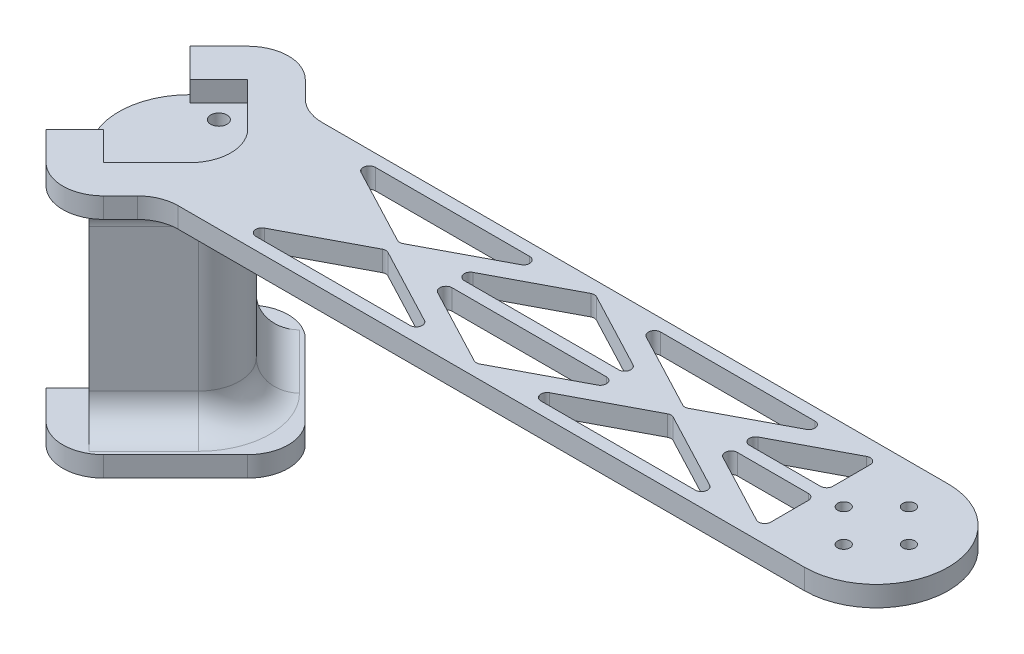
from build123d import *

# Parameters (mm, degrees)
SKETCH1_R            = 1.5
BOSS_EXTRUDE1_DEPTH  = 5
SKETCH2_R            = 2
BOSS_EXTRUDE13_DEPTH = 50
FILLET3_R            = 10
FILLET8_R            = 7.5
BOSS_EXTRUDE14_DEPTH = 5
FILLET9_R            = 7.5


with BuildPart() as part:
    # Sketch1 → Boss-Extrude1 (new body)
    with BuildSketch(Plane(origin=(0, 0, 0), x_dir=(1, 0, 0), z_dir=(0, 1, 0))):
        with BuildLine():
            Line((-7.071067812, -7.071067812), (-17.67766953, -17.67766953))
            Line((-17.67766953, -17.67766953), (-24.748737342, -10.606601718))
            Line((-24.748737342, -10.606601718), (-31.819805153, -17.67766953))
            Line((-31.819805153, -17.67766953), (-24.748737342, -24.748737342))
            ThreePointArc((-24.748737342, -24.748737342), (-17.67766953, -27.67766953), (-10.606601718, -24.748737342))
            Line((-10.606601718, -24.748737342), (-6.464466135, -20.606601758))
            ThreePointArc((-6.464466135, -20.606601758), (-3.220232647, -18.438874245), (0.606601677, -17.67766957))
            Line((0.606601677, -17.67766957), (154.3, -17.67766957))
            ThreePointArc((154.3, -17.67766957), (171.97766953, 0), (154.3, 17.67766953))
            Line((154.3, 17.67766953), (0.606601718, 17.67766953))
            ThreePointArc((0.606601718, 17.67766953), (-3.220232606, 18.438874205), (-6.464466094, 20.606601718))
            Line((-6.464466094, 20.606601718), (-10.606601718, 24.748737342))
            ThreePointArc((-10.606601718, 24.748737342), (-17.67766953, 27.67766953), (-24.748737342, 24.748737342))
            Line((-24.748737342, 24.748737342), (-31.819805153, 17.67766953))
            Line((-31.819805153, 17.67766953), (-24.748737342, 10.606601718))
            Line((-24.748737342, 10.606601718), (-17.67766953, 17.67766953))
            Line((-17.67766953, 17.67766953), (-7.071067812, 7.071067812))
            ThreePointArc((-7.071067812, 7.071067812), (-4.142135624, 0), (-7.071067812, -7.071067812))
        make_face()
        with Locations(Location((146.3, 0, 0), (0, 0, 270))):
            Circle(SKETCH1_R, mode=Mode.SUBTRACT)
        with Locations(Location((154.3, -8, 0), (0, 0, 270))):
            Circle(SKETCH1_R, mode=Mode.SUBTRACT)
        with Locations(Location((162.3, 0, 0), (0, 0, 270))):
            Circle(SKETCH1_R, mode=Mode.SUBTRACT)
        with Locations(Location((154.3, 8, 0), (0, 0, 270))):
            Circle(SKETCH1_R, mode=Mode.SUBTRACT)
        with BuildLine():
            Line((15.969736075, 11.850725041), (34.90716028, 1.868680325))
            ThreePointArc((34.90716028, 1.868680325), (35.606601718, 1.695624813), (36.306043156, 1.868680325))
            Line((36.306043156, 1.868680325), (55.24346736, 11.850725041))
            ThreePointArc((55.24346736, 11.850725041), (56.000119452, 13.537935589), (54.544025922, 14.67766953))
            Line((54.544025922, 14.67766953), (16.669177513, 14.67766953))
            ThreePointArc((16.669177513, 14.67766953), (15.213083984, 13.537935589), (15.969736075, 11.850725041))
        make_face(mode=Mode.SUBTRACT)
        with BuildLine():
            Line((50.969736075, 4.326944488), (69.90716028, 14.308989205))
            ThreePointArc((69.90716028, 14.308989205), (70.606601718, 14.482044716), (71.306043156, 14.308989205))
            Line((71.306043156, 14.308989205), (90.24346736, 4.326944488))
            ThreePointArc((90.24346736, 4.326944488), (91.000119452, 2.63973394), (89.544025922, 1.5))
            Line((89.544025922, 1.5), (51.669177513, 1.5))
            ThreePointArc((51.669177513, 1.5), (50.213083984, 2.63973394), (50.969736075, 4.326944488))
        make_face(mode=Mode.SUBTRACT)
        with BuildLine():
            Line((85.969736075, 11.850725041), (104.90716028, 1.868680325))
            ThreePointArc((104.90716028, 1.868680325), (105.606601718, 1.695624813), (106.306043156, 1.868680325))
            Line((106.306043156, 1.868680325), (125.24346736, 11.850725041))
            ThreePointArc((125.24346736, 11.850725041), (126.000119452, 13.537935589), (124.544025922, 14.67766953))
            Line((124.544025922, 14.67766953), (86.669177513, 14.67766953))
            ThreePointArc((86.669177513, 14.67766953), (85.213083984, 13.537935589), (85.969736075, 11.850725041))
        make_face(mode=Mode.SUBTRACT)
        with BuildLine():
            Line((120.969736075, 4.326944488), (138.40716028, 13.518329033))
            ThreePointArc((138.40716028, 13.518329033), (139.881468753, 13.475744727), (140.606601718, 12.191384545))
            Line((140.606601718, 12.191384545), (140.606601718, 3))
            ThreePointArc((140.606601718, 3), (140.16726189, 1.939339828), (139.106601718, 1.5))
            Line((139.106601718, 1.5), (121.669177513, 1.5))
            ThreePointArc((121.669177513, 1.5), (120.213083984, 2.63973394), (120.969736075, 4.326944488))
        make_face(mode=Mode.SUBTRACT)
        with BuildLine():
            Line((140.606601718, -12.191384545), (140.606601718, -3))
            ThreePointArc((140.606601718, -3), (140.16726189, -1.939339828), (139.106601718, -1.5))
            Line((139.106601718, -1.5), (121.669177513, -1.5))
            ThreePointArc((121.669177513, -1.5), (120.213083984, -2.63973394), (120.969736075, -4.326944488))
            Line((120.969736075, -4.326944488), (138.40716028, -13.518329033))
            ThreePointArc((138.40716028, -13.518329033), (139.881468753, -13.475744727), (140.606601718, -12.191384545))
        make_face(mode=Mode.SUBTRACT)
        with BuildLine():
            Line((124.544025922, -14.67766953), (86.669177513, -14.67766953))
            ThreePointArc((86.669177513, -14.67766953), (85.213083984, -13.537935589), (85.969736075, -11.850725041))
            Line((85.969736075, -11.850725041), (104.90716028, -1.868680325))
            ThreePointArc((104.90716028, -1.868680325), (105.606601718, -1.695624813), (106.306043156, -1.868680325))
            Line((106.306043156, -1.868680325), (125.24346736, -11.850725041))
            ThreePointArc((125.24346736, -11.850725041), (126.000119452, -13.537935589), (124.544025922, -14.67766953))
        make_face(mode=Mode.SUBTRACT)
        with BuildLine():
            Line((71.306043156, -14.308989205), (90.24346736, -4.326944488))
            ThreePointArc((90.24346736, -4.326944488), (91.000119452, -2.63973394), (89.544025922, -1.5))
            Line((89.544025922, -1.5), (51.669177513, -1.5))
            ThreePointArc((51.669177513, -1.5), (50.213083984, -2.63973394), (50.969736075, -4.326944488))
            Line((50.969736075, -4.326944488), (69.90716028, -14.308989205))
            ThreePointArc((69.90716028, -14.308989205), (70.606601718, -14.482044716), (71.306043156, -14.308989205))
        make_face(mode=Mode.SUBTRACT)
        with BuildLine():
            Line((36.306043156, -1.868680325), (55.24346736, -11.850725041))
            ThreePointArc((55.24346736, -11.850725041), (56.000119452, -13.537935589), (54.544025922, -14.67766953))
            Line((54.544025922, -14.67766953), (16.669177513, -14.67766953))
            ThreePointArc((16.669177513, -14.67766953), (15.213083984, -13.537935589), (15.969736075, -11.850725041))
            Line((15.969736075, -11.850725041), (34.90716028, -1.868680325))
            ThreePointArc((34.90716028, -1.868680325), (35.606601718, -1.695624813), (36.306043156, -1.868680325))
        make_face(mode=Mode.SUBTRACT)
    extrude(amount=BOSS_EXTRUDE1_DEPTH)

    # Sketch2 → Boss-Extrude13 (add)
    with BuildSketch(Plane.XZ):
        with BuildLine():
            Line((2.121320344, 0), (-18.384776311, 20.506096654))
            Line((-18.384776311, 20.506096654), (-26.516504294, 12.374368671))
            ThreePointArc((-26.516504294, 12.374368671), (-31.642135624, 0), (-26.516504294, -12.374368671))
            Line((-26.516504294, -12.374368671), (-18.384776311, -20.506096654))
            Line((-18.384776311, -20.506096654), (2.121320344, 0))
        make_face()
        Polygon((-24.748737342, -10.606601718), (-24.748737342, 10.606601718), (-21.213203436, 14.142135624), (-17.67766953, 17.67766953), (0, 0), (-17.67766953, -17.67766953), (-21.213203436, -14.142135624), align=None, mode=Mode.SUBTRACT)
        Polygon((-21.213203436, 14.142135624), (-24.748737342, 10.606601718), (-24.748737342, -10.606601718), (-21.213203436, -14.142135624), (-17.67766953, -17.67766953), (0, 0), (-17.67766953, 17.67766953), align=None)
        with Locations(Location((-17.67766953, -10.606601718, 0), (0, 0, 270))):
            Circle(SKETCH2_R, mode=Mode.SUBTRACT)
        with Locations(Location((-17.67766953, 10.606601718, 0), (0, 0, 270))):
            Circle(SKETCH2_R, mode=Mode.SUBTRACT)
    extrude(amount=BOSS_EXTRUDE13_DEPTH)

    # Fillet3
    fillet3_edges = [part.edges().sort_by_distance(p)[0] for p in [
        (2.121320344, -25, 0),
    ]]
    fillet(fillet3_edges, radius=FILLET3_R)

    # Fillet8
    fillet8_edges = [part.edges().sort_by_distance(p)[0] for p in [
        (-11.66726189, 0, 13.788582233),
        (-11.66726189, 0, -13.788582233),
        (-2.02081528, 0, 0),
    ]]
    fillet(fillet8_edges, radius=FILLET8_R)

    # Sketch3 → Boss-Extrude14 (add)
    with BuildSketch(Plane.XZ.offset(50)):
        with BuildLine():
            Line((-7.071067812, -7.071067812), (-17.67766953, -17.67766953))
            Line((-17.67766953, -17.67766953), (-24.748737342, -10.606601718))
            Line((-24.748737342, -10.606601718), (-31.819805153, -17.67766953))
            Line((-31.819805153, -17.67766953), (-24.760321052, -24.737153631))
            ThreePointArc((-24.760321052, -24.737153631), (-17.68925324, -27.666085819), (-10.618185428, -24.737153631))
            Line((-10.618185428, -24.737153631), (7.059484102, -7.059484102))
            ThreePointArc((7.059484102, -7.059484102), (9.98841629, 0.01158371), (7.059484102, 7.082651522))
            Line((7.059484102, 7.082651522), (-10.606601718, 24.748737342))
            ThreePointArc((-10.606601718, 24.748737342), (-17.67766953, 27.67766953), (-24.748737342, 24.748737342))
            Line((-24.748737342, 24.748737342), (-31.819805153, 17.67766953))
            Line((-31.819805153, 17.67766953), (-24.748737342, 10.606601718))
            Line((-24.748737342, 10.606601718), (-17.67766953, 17.67766953))
            Line((-17.67766953, 17.67766953), (-7.071067812, 7.071067812))
            ThreePointArc((-7.071067812, 7.071067812), (-4.142135624, 0), (-7.071067812, -7.071067812))
        make_face()
    extrude(amount=BOSS_EXTRUDE14_DEPTH)

    # Fillet9
    fillet9_edges = [part.edges().sort_by_distance(p)[0] for p in [
        (-11.66726189, -50, 13.788582233),
        (-11.66726189, -50, -13.788582233),
        (-2.02081528, -50, 0),
    ]]
    fillet(fillet9_edges, radius=FILLET9_R)


solid = part.part
